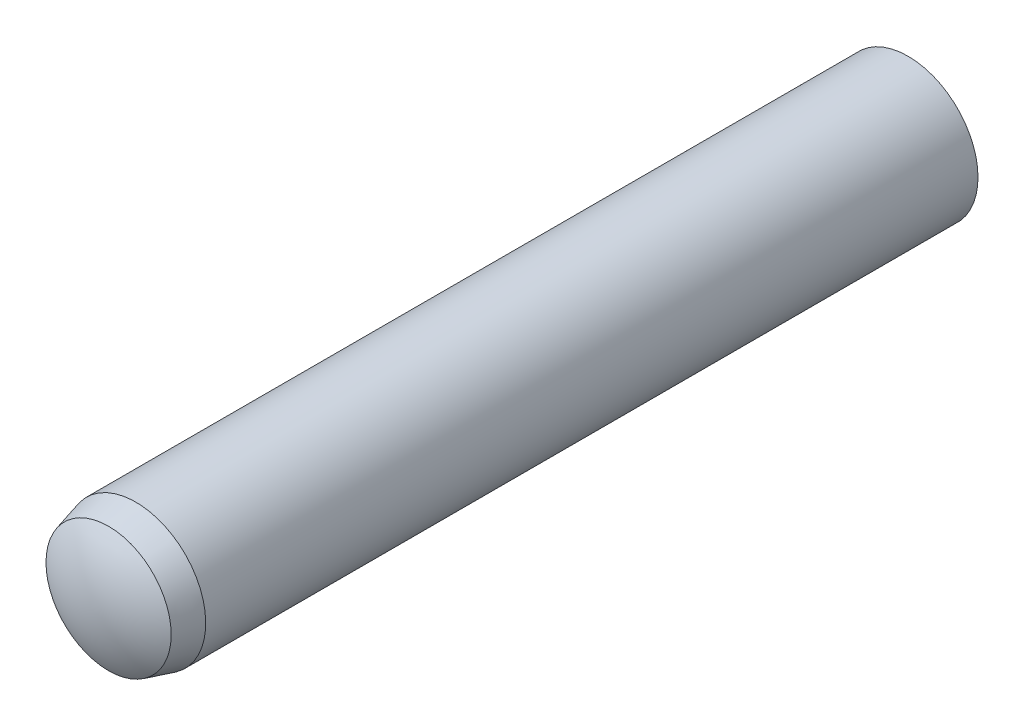
from build123d import *


with BuildPart() as part:
    # Sketch3 → Revolve1 (revolve)
    with BuildSketch(Plane(origin=(0, 0, 0), x_dir=(0, 0, -1), z_dir=(1, 0, 0))):
        with BuildLine():
            Line((-6, 0), (6, 0))
            ThreePointArc((6, 0), (5.923384418, 0.522015325), (5.7, 1))
            Line((5.7, 1), (-5.35, 1))
            Line((-5.35, 1), (-5.74, 0.895499815))
            ThreePointArc((-5.74, 0.895499815), (-5.933685026, 0.46624026), (-6, 0))
        make_face()
    revolve(axis=Axis((0, 0, 6), (0, 0, -1)))


solid = part.part
